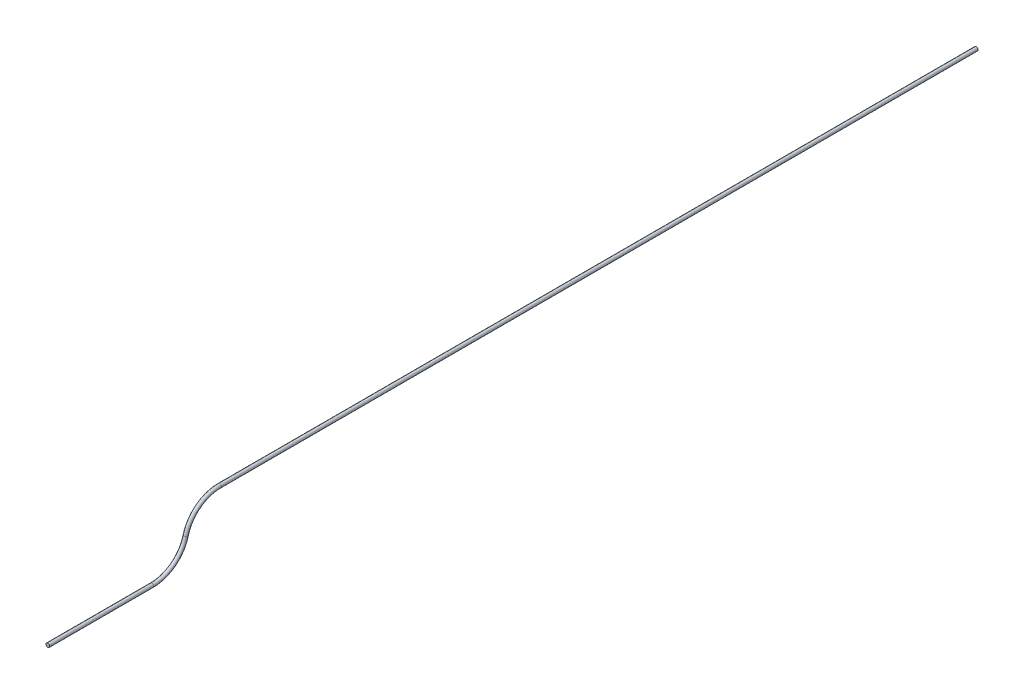
from build123d import *

# Parameters (mm, degrees)
SKETCH1_R = 4.03225


with BuildPart() as part:
    # Sweep1: sweep along a path in Sketch2
    with BuildLine(Plane(origin=(0, 0, 0), x_dir=(0, 0, -1), z_dir=(1, 0, 0))) as sweep1_path:
        Line((0, 0), (227, 0))
        ThreePointArc((227, 0), (273.6627796, 15.958610574), (300.780332745, 57.15))
        ThreePointArc((300.780332745, 57.15), (327.89788589, 98.341389426), (374.560665491, 114.3))
        Line((374.560665491, 114.3), (2025.560665491, 114.3))
    # Sketch1 → Sweep1 (sweep)
    with BuildSketch(Plane.XY):
        Circle(SKETCH1_R)
    sweep(path=sweep1_path.line)


solid = part.part
